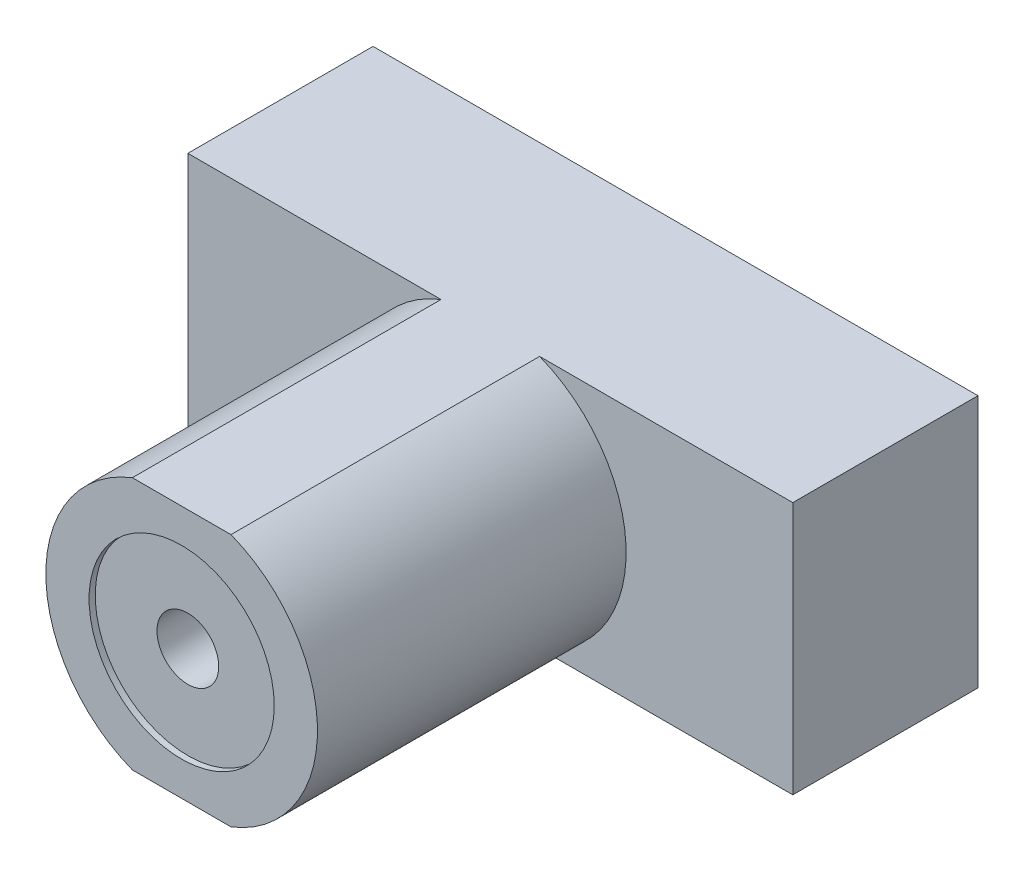
from build123d import *

# Parameters (mm, degrees)
COMPONENT_OUTLINE_W = 9.8
COMPONENT_OUTLINE_H = 4.1
EXTRUDE1_DEPTH      = 8
CUT_EXTRUDE1_DEPTH  = 5
SKETCH3_R           = 0.5
CUT_EXTRUDE2_DEPTH  = 5
SKETCH4_R           = 1.5
CUT_EXTRUDE3_DEPTH  = 0.1


with BuildPart() as part:
    # COMPONENT_OUTLINE → Extrude1 (new body)
    with BuildSketch(Plane.XY):
        with Locations((0, -3.45)):
            Rectangle(COMPONENT_OUTLINE_W, COMPONENT_OUTLINE_H)
    extrude(amount=EXTRUDE1_DEPTH)

    # Sketch1 → Cut-Extrude1 (cut)
    with BuildSketch(Plane.XY.offset(8)):
        with BuildLine():
            Line((0.798435971, -5.5), (4.9, -5.5))
            Line((4.9, -5.5), (4.9, -1.4))
            Line((4.9, -1.4), (0.798435971, -1.4))
            ThreePointArc((0.798435971, -1.4), (2.2, -3.45), (0.798435971, -5.5))
        make_face()
        with BuildLine():
            Line((-0.798435971, -1.4), (-4.9, -1.4))
            Line((-4.9, -1.4), (-4.9, -5.5))
            Line((-4.9, -5.5), (-0.798435971, -5.5))
            ThreePointArc((-0.798435971, -5.5), (-2.2, -3.45), (-0.798435971, -1.4))
        make_face()
    extrude(amount=-CUT_EXTRUDE1_DEPTH, mode=Mode.SUBTRACT)

    # Sketch3 → Cut-Extrude2 (cut)
    with BuildSketch(Plane.XY.offset(8)):
        with Locations((0, -3.45)):
            Circle(SKETCH3_R)
    extrude(amount=-CUT_EXTRUDE2_DEPTH, mode=Mode.SUBTRACT)

    # Sketch4 → Cut-Extrude3 (cut)
    with BuildSketch(Plane.XY.offset(8)):
        with Locations((0, -3.45)):
            Circle(SKETCH4_R)
    extrude(amount=-CUT_EXTRUDE3_DEPTH, mode=Mode.SUBTRACT)


solid = part.part
